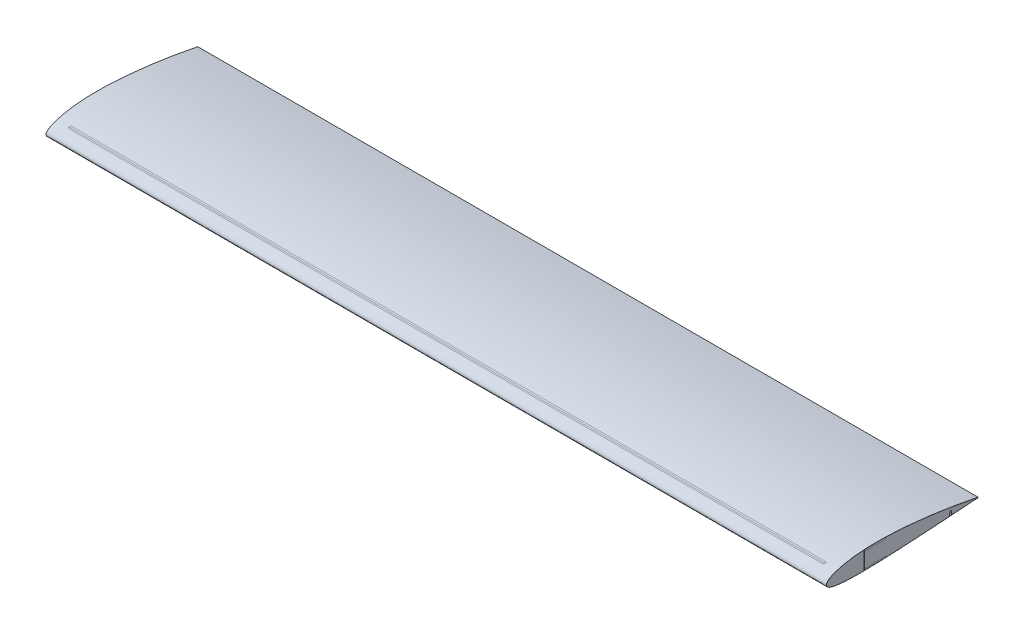
from build123d import *

# Parameters (mm, degrees)
BOSS_EXTRUDE1_DEPTH      = 914.4
SPLIT1_SURFACE_1_1_BACK  = 1864.333
SPLIT1_SURFACE_1_1_DEPTH = 3728.666
SPLIT1_SURFACE_1_2_BACK  = 1864.333
SPLIT1_SURFACE_1_2_DEPTH = 3728.666
SPLIT1_SURFACE_2_3_BACK  = 1864.333
SPLIT1_SURFACE_2_3_DEPTH = 3728.666
SPLIT1_SURFACE_2_4_BACK  = 1864.333
SPLIT1_SURFACE_2_4_DEPTH = 3728.666
CUT_EXTRUDE2_DEPTH       = 1864.047955072
CUT_EXTRUDE2_DEPTH_BACK  = 1864.047955072
SKETCH5_W                = 0.6096
SKETCH5_H                = 41.97587398
BOSS_EXTRUDE3_DEPTH      = 914.4
CUT_EXTRUDE1_DEPTH       = 982.342251229
CUT_EXTRUDE1_DEPTH_BACK  = 982.342251229
CUT_EXTRUDE3_START       = -15.24
SKETCH7_W                = 88.9
SKETCH7_H                = 50.8
SKETCH7_W_2              = 70
SKETCH7_H_2              = 60
CUT_EXTRUDE3_DEPTH       = 30


with BuildPart() as part:
    # Sketch3 → Boss-Extrude1 (new, symmetric)
    with BuildSketch(Plane(origin=(0, 0, 0), x_dir=(0, 0, -1), z_dir=(1, 0, 0))):
        with BuildLine():
            Line((354.482395792, 0.088620593), (354.482404208, -0.088620593))
            add(Edge.make_bspline(
                [(354.482395792, 0.088620593), (352.608228452, 0.482962912), (348.863032635, 1.270987104), (343.239204367, 2.400705172), (337.619234196, 3.501205803), (332.00350741, 4.57336723), (326.39365094, 5.621708723), (320.790955975, 6.647898692), (313.3412437, 7.986206456), (302.217548708, 9.927124821), (289.282248172, 12.069306379), (276.418289617, 14.074375479), (265.490213834, 15.689685159), (251.115583129, 17.697647921), (236.873997635, 19.516706822), (222.782191073, 21.1545078), (212.410278806, 22.282196191), (202.181522544, 23.317263374), (192.106178265, 24.258738007), (182.194355765, 25.104010981), (172.455993609, 25.84914195), (161.366752116, 26.592136123), (149.021873138, 27.260173986), (135.523535242, 27.752901504), (122.520585026, 27.971703259), (110.042618811, 27.912632335), (99.358952427, 27.613925108), (90.383015498, 27.176611302), (83.018255857, 26.691704891), (75.92680001, 26.098801968), (69.115792956, 25.403560206), (62.592086687, 24.612075224), (56.362219308, 23.730740073), (50.432432253, 22.76613435), (44.808681252, 21.725005613), (39.496589414, 20.614286523), (35.273389174, 19.622414223), (31.312122611, 18.607678857), (28.30479813, 17.772072592), (25.414040275, 16.897477013), (23.365017286, 16.242283662), (21.399313086, 15.577802598), (19.517418849, 14.904921007), (17.719798231, 14.224519318), (16.006896794, 13.537442329), (14.379132199, 12.844514757), (12.83689884, 12.146526839), (11.380573945, 11.444212218), (10.010495431, 10.738285126), (8.72699723, 10.029363811), (7.530365935, 9.318048232), (6.420876343, 8.604847497), (5.398771977, 7.890203754), (4.464271107, 7.174487774), (3.617571137, 6.457983471), (2.858851273, 5.740891979), (2.188290996, 5.02331412), (1.606069933, 4.305271505), (1.112414132, 3.586696787), (0.707594428, 2.867468864), (0.392035275, 2.147467241), (0.165980955, 1.426648517), (0.03064104, 0.705108282), (-0.015062322, 0.002321998), (0.0300091, -0.681067808), (0.166233189, -1.342726293), (0.392064116, -1.999419221), (0.707750679, -2.648952207), (1.11267333, -3.289391709), (1.606518652, -3.919009399), (2.188985401, -4.536239368), (2.859837198, -5.139669278), (3.618875057, -5.728012998), (4.465910314, -6.300126202), (5.400751117, -6.855005762), (6.423189663, -7.391813529), (7.532996553, -7.909871987), (8.729927186, -8.408651764), (10.013701883, -8.887797325), (11.38402716, -9.347075258), (12.840573178, -9.786424712), (14.382996464, -10.205871846), (16.010922843, -10.605571954), (17.723957882, -10.985755667), (19.521682855, -11.346729932), (21.403657483, -11.688838297), (23.369418393, -12.012454984), (25.418477351, -12.317982315), (27.550327067, -12.60579833), (29.764437774, -12.876267774), (32.06025868, -13.129726833), (35.281637131, -13.450564772), (39.508953014, -13.807595259), (44.820372176, -14.165273739), (50.443395574, -14.459314626), (56.372426035, -14.689735484), (62.601520751, -14.856376302), (69.124436068, -14.959259527), (75.934620245, -14.999005808), (83.025208132, -14.977114302), (90.389050421, -14.896168064), (98.01873047, -14.759786253), (105.906589977, -14.572414932), (114.044705159, -14.338950875), (122.424896468, -14.064247122), (131.038747414, -13.752531546), (139.877603076, -13.406970238), (148.932577206, -13.029259309), (161.41234267, -12.47716831), (174.14861492, -11.863755741), (187.128161714, -11.181855227), (197.122814271, -10.626100485), (207.275853505, -10.030722137), (219.334002974, -9.289918707), (231.549233078, -8.503762909), (243.909719078, -7.688473483), (254.646983505, -6.974941746), (263.659566191, -6.37740606), (272.749168182, -5.777991417), (281.906666981, -5.177313299), (292.948412975, -4.453461563), (302.190318, -3.838787226), (309.611800723, -3.332601249), (315.195965568, -2.943756386), (320.789989327, -2.54505907), (326.392440618, -2.136294162), (332.001878993, -1.718848953), (337.616855999, -1.295823565), (343.235982568, -0.874824171), (348.857573789, -0.461772871), (352.607516747, -0.21300097), (354.482404208, -0.088620593)],
                knots=[0, 0, 0, 0, 0.007940543, 0.015867786, 0.023782336, 0.031683842, 0.039571466, 0.047443805, 0.055299407, 0.070952907, 0.094259966, 0.109659749, 0.124931368, 0.140060475, 0.169836167, 0.184455938, 0.198878988, 0.213091981, 0.227081364, 0.240833733, 0.254335896, 0.267574898, 0.286913018, 0.305591757, 0.323574751, 0.340828862, 0.357323531, 0.367884026, 0.378086462, 0.387923234, 0.397387015, 0.406470797, 0.41516795, 0.423472244, 0.43137777, 0.438879022, 0.445971139, 0.449362331, 0.455832514, 0.458910652, 0.461883669, 0.464751272, 0.467513247, 0.470169459, 0.472719872, 0.475164567, 0.477503762, 0.479737826, 0.481867333, 0.483893084, 0.485816152, 0.487637951, 0.489360303, 0.49098553, 0.492516542, 0.493957004, 0.495311466, 0.496585561, 0.4977862, 0.498921787, 0.500002352, 0.50103964, 0.502046987, 0.503038995, 0.503951731, 0.504878158, 0.505831393, 0.506823576, 0.507865603, 0.508967032, 0.510136107, 0.511379885, 0.512704371, 0.51411466, 0.515615093, 0.517209348, 0.518900571, 0.520691419, 0.522584144, 0.524580638, 0.526682478, 0.528890964, 0.531207133, 0.533631806, 0.536165599, 0.538808937, 0.541562081, 0.544425147, 0.547398108, 0.550480817, 0.553673027, 0.556974385, 0.563902733, 0.571261381, 0.579045037, 0.58724742, 0.595861595, 0.604880098, 0.614294871, 0.624097261, 0.634278056, 0.644827522, 0.655735355, 0.666990799, 0.678582536, 0.690498843, 0.702727789, 0.715257042, 0.728074047, 0.754520377, 0.768123571, 0.781962351, 0.796022904, 0.810291085, 0.832050541, 0.846772874, 0.861649926, 0.876666219, 0.884221743, 0.899417941, 0.914715475, 0.9300999, 0.937820202, 0.945556969, 0.953308312, 0.961072259, 0.968846879, 0.976629764, 0.984418334, 0.992209516, 1, 1, 1, 1], degree=3))
        make_face()
    extrude(amount=BOSS_EXTRUDE1_DEPTH, both=True)


with BuildPart() as body_2:
    # Split1: the piece behind the surface
    add(part.part)
    # Split1 surface 1: a surface, the sketch's curves swept straight by 3728.666 mm
    with BuildLine(Plane(origin=(914.4, 0, 0), x_dir=(0, 0, -1), z_dir=(1, 0, 0)).offset(-SPLIT1_SURFACE_1_1_BACK), mode=Mode.PRIVATE) as split1_surface_1_1_path:
        Line((139.692248422, -14.02064701), (139.692248422, -10.84564701))
        Line((139.692248422, -10.84564701), (88.9, -11.733059128))
        Line((88.9, -11.733059128), (88.9, -14.908059128))
    split1_surface_1_1 = Shell.extrude(split1_surface_1_1_path.wire(), (1 * SPLIT1_SURFACE_1_1_DEPTH, 0 * SPLIT1_SURFACE_1_1_DEPTH, 0 * SPLIT1_SURFACE_1_1_DEPTH))
    split(bisect_by=split1_surface_1_1, keep=Keep.BOTTOM)


with BuildPart() as part_1:
    add(part.part)

    # Split1: split by a surface, the side it looks to stays
    # Split1 surface 1: a surface, the sketch's curves swept straight by 3728.666 mm
    with BuildLine(Plane(origin=(914.4, 0, 0), x_dir=(0, 0, -1), z_dir=(1, 0, 0)).offset(-SPLIT1_SURFACE_1_2_BACK), mode=Mode.PRIVATE) as split1_surface_1_2_path:
        Line((139.692248422, -14.02064701), (139.692248422, -10.84564701))
        Line((139.692248422, -10.84564701), (88.9, -11.733059128))
        Line((88.9, -11.733059128), (88.9, -14.908059128))
    split1_surface_1_2 = Shell.extrude(split1_surface_1_2_path.wire(), (1 * SPLIT1_SURFACE_1_2_DEPTH, 0 * SPLIT1_SURFACE_1_2_DEPTH, 0 * SPLIT1_SURFACE_1_2_DEPTH))
    split(bisect_by=split1_surface_1_2, keep=Keep.TOP)


with BuildPart() as body_3:
    # Split1 2 body 2: the piece behind the surface
    add(body_2.part)
    # Split1 surface 2: a surface, the sketch's curves swept straight by 3728.666 mm
    with BuildLine(Plane(origin=(914.4, 0, 0), x_dir=(0, 0, -1), z_dir=(1, 0, 0)).offset(-SPLIT1_SURFACE_2_3_BACK), mode=Mode.PRIVATE) as split1_surface_2_3_path:
        Line((139.7, 27.585057341), (139.7, 23.892814852))
        Line((139.7, 23.892814852), (88.9, 23.892814852))
        Line((88.9, 23.892814852), (88.9, 27.067814852))
    split1_surface_2_3 = Shell.extrude(split1_surface_2_3_path.wire(), (1 * SPLIT1_SURFACE_2_3_DEPTH, 0 * SPLIT1_SURFACE_2_3_DEPTH, 0 * SPLIT1_SURFACE_2_3_DEPTH))
    split(bisect_by=split1_surface_2_3, keep=Keep.BOTTOM)


with BuildPart() as body_2_1:
    add(body_2.part)

    # Split1 2 body 2: split by a surface, the side it looks to stays
    # Split1 surface 2: a surface, the sketch's curves swept straight by 3728.666 mm
    with BuildLine(Plane(origin=(914.4, 0, 0), x_dir=(0, 0, -1), z_dir=(1, 0, 0)).offset(-SPLIT1_SURFACE_2_4_BACK), mode=Mode.PRIVATE) as split1_surface_2_4_path:
        Line((139.7, 27.585057341), (139.7, 23.892814852))
        Line((139.7, 23.892814852), (88.9, 23.892814852))
        Line((88.9, 23.892814852), (88.9, 27.067814852))
    split1_surface_2_4 = Shell.extrude(split1_surface_2_4_path.wire(), (1 * SPLIT1_SURFACE_2_4_DEPTH, 0 * SPLIT1_SURFACE_2_4_DEPTH, 0 * SPLIT1_SURFACE_2_4_DEPTH))
    split(bisect_by=split1_surface_2_4, keep=Keep.TOP)

    # Sketch5 → Cut-Extrude2 (cut, two sides: drawn at the far end of the back side and taken through both)
    with BuildSketch(Plane(origin=(914.4, 0, 0), x_dir=(0, 0, -1), z_dir=(1, 0, 0)).offset(-CUT_EXTRUDE2_DEPTH_BACK)):
        with Locations((88.5952, 6.079877862)):
            Rectangle(SKETCH5_W, SKETCH5_H)
    extrude(amount=CUT_EXTRUDE2_DEPTH + CUT_EXTRUDE2_DEPTH_BACK, mode=Mode.SUBTRACT)


with BuildPart() as cut_extrude2_piece_1:
    # of the separate pieces the step leaves, piece 1, a body of its own (cut_extrude2_pieces)
    add(body_2_1.part.solids().sort_by_distance((0, 0.088620593, -354.482395792))[0])

    # Sketch3_3 → Cut-Extrude1 (cut, two sides: drawn at the far end of the back side and taken through both)
    with BuildSketch(Plane(origin=(0, 0, 0), x_dir=(0, 0, -1), z_dir=(1, 0, 0)).offset(-CUT_EXTRUDE1_DEPTH_BACK)):
        Polygon((290.9824, 7.62), (287.654397763, -4.800273435), (290.9824, -6.35), (294.194928457, -4.369319423), align=None)
    extrude(amount=CUT_EXTRUDE1_DEPTH + CUT_EXTRUDE1_DEPTH_BACK, mode=Mode.SUBTRACT)


with BuildPart() as cut_extrude2_piece_2:
    # of the separate pieces the step leaves, piece 2, a body of its own (cut_extrude2_pieces)
    add(body_2_1.part.solids().sort_by_distance((-914.4, 27.030418138, -88.2904))[0])


with BuildPart() as body_5:
    # Sketch3_4 → Boss-Extrude3 (new, symmetric)
    with BuildSketch(Plane(origin=(0, 0, 0), x_dir=(0, 0, -1), z_dir=(1, 0, 0))):
        with BuildLine():
            Line((355.091972301, 0.583307998), (355.0920313, -0.659117779))
            add(Edge.make_bspline(
                [(355.091972301, 0.583307998), (340.312721276, 3.693000498), (310.619909788, 9.275193539), (265.886786743, 16.489468956), (228.423488563, 21.249575809), (198.375428006, 24.346944526), (175.800462925, 26.279897889), (153.185851558, 27.734389131), (130.534341141, 28.566890102), (111.639670243, 28.595066064), (96.53057426, 28.120840782), (85.209090536, 27.490139036), (73.906703798, 26.554481442), (62.635164397, 25.277209771), (51.411056679, 23.609637495), (42.117578054, 21.837331865), (34.74012523, 20.134439319), (29.24437833, 18.69364882), (23.79825163, 17.061014615), (18.420286663, 15.195924919), (13.14366618, 13.032592163), (8.880173336, 10.889148982), (5.630848338, 8.846659986), (3.323741515, 7.086461913), (1.245271009, 5.003310853), (-0.100437746, 2.836873377), (-0.523145833, 1.190618683), (-0.61337565, 0.27223844), (-0.614549748, -0.263820978), (-0.519523355, -1.17728836), (-0.186155394, -2.32203817), (0.846863121, -4.107713514), (2.649273044, -5.870048972), (5.118512155, -7.455426547), (7.737103362, -8.698049302), (11.332776407, -10.034608615), (15.937246254, -11.276874703), (21.529341018, -12.368534166), (27.15473911, -13.195901809), (32.797240174, -13.837752171), (40.333864658, -14.507839139), (49.769089576, -15.075023465), (61.099652807, -15.458479805), (72.432280744, -15.614977761), (83.76344512, -15.594566474), (95.091473866, -15.436956689), (109.964247113, -15.092784384), (122.943936948, -14.66400478), (135.920562744, -14.174609397), (143.690347914, -13.860725655), (157.116288121, -13.285023495), (174.310683531, -12.480653893), (196.927788923, -11.269252396), (227.071310703, -9.442589353), (257.19655476, -7.405393554), (287.324528389, -5.43433642), (309.922117903, -3.947040671), (332.514912298, -2.303371631), (347.562013118, -1.158660561), (355.0920313, -0.659117779)],
                knots=[-0.000683627, -0.000683627, -0.000683627, -0.000683627, 0.06190838, 0.124500386, 0.187092393, 0.218388396, 0.249684399, 0.280980403, 0.312276406, 0.343572409, 0.359220411, 0.374868413, 0.390516414, 0.406164416, 0.421812418, 0.437460419, 0.44528442, 0.453108421, 0.460932422, 0.468756423, 0.476580423, 0.484404424, 0.488316425, 0.492228425, 0.496140425, 0.500052426, 0.502008426, 0.502526747, 0.503504747, 0.503993747, 0.505920426, 0.507876427, 0.511788427, 0.515700428, 0.519612428, 0.523524428, 0.531348429, 0.53917243, 0.546996431, 0.554820432, 0.562644432, 0.578292434, 0.593940436, 0.609588437, 0.625236439, 0.640884441, 0.656532442, 0.686889741, 0.694713742, 0.710361744, 0.719124449, 0.750420452, 0.781716456, 0.813012459, 0.875604465, 0.906900469, 0.938196472, 0.969492475, 1.000788479, 1.000788479, 1.000788479, 1.000788479], degree=3))
        make_face()
        with BuildLine():
            Line((354.482395792, 0.088620593), (354.482404208, -0.088620593))
            add(Edge.make_bspline(
                [(354.482395792, 0.088620593), (352.608228452, 0.482962912), (348.863032635, 1.270987104), (343.239204367, 2.400705172), (337.619234196, 3.501205803), (332.00350741, 4.57336723), (326.39365094, 5.621708723), (320.790955975, 6.647898692), (313.3412437, 7.986206456), (302.217548708, 9.927124821), (289.282248172, 12.069306379), (276.418289617, 14.074375479), (265.490213834, 15.689685159), (251.115583129, 17.697647921), (236.873997635, 19.516706822), (222.782191073, 21.1545078), (212.410278806, 22.282196191), (202.181522544, 23.317263374), (192.106178265, 24.258738007), (182.194355765, 25.104010981), (172.455993609, 25.84914195), (161.366752116, 26.592136123), (149.021873138, 27.260173986), (135.523535242, 27.752901504), (122.520585026, 27.971703259), (110.042618811, 27.912632335), (99.358952427, 27.613925108), (90.383015498, 27.176611302), (83.018255857, 26.691704891), (75.92680001, 26.098801968), (69.115792956, 25.403560206), (62.592086687, 24.612075224), (56.362219308, 23.730740073), (50.432432253, 22.76613435), (44.808681252, 21.725005613), (39.496589414, 20.614286523), (35.273389174, 19.622414223), (31.312122611, 18.607678857), (28.30479813, 17.772072592), (25.414040275, 16.897477013), (23.365017286, 16.242283662), (21.399313086, 15.577802598), (19.517418849, 14.904921007), (17.719798231, 14.224519318), (16.006896794, 13.537442329), (14.379132199, 12.844514757), (12.83689884, 12.146526839), (11.380573945, 11.444212218), (10.010495431, 10.738285126), (8.72699723, 10.029363811), (7.530365935, 9.318048232), (6.420876343, 8.604847497), (5.398771977, 7.890203754), (4.464271107, 7.174487774), (3.617571137, 6.457983471), (2.858851273, 5.740891979), (2.188290996, 5.02331412), (1.606069933, 4.305271505), (1.112414132, 3.586696787), (0.707594428, 2.867468864), (0.392035275, 2.147467241), (0.165980955, 1.426648517), (0.03064104, 0.705108282), (-0.015062322, 0.002321998), (0.0300091, -0.681067808), (0.166233189, -1.342726293), (0.392064116, -1.999419221), (0.707750679, -2.648952207), (1.11267333, -3.289391709), (1.606518652, -3.919009399), (2.188985401, -4.536239368), (2.859837198, -5.139669278), (3.618875057, -5.728012998), (4.465910314, -6.300126202), (5.400751117, -6.855005762), (6.423189663, -7.391813529), (7.532996553, -7.909871987), (8.729927186, -8.408651764), (10.013701883, -8.887797325), (11.38402716, -9.347075258), (12.840573178, -9.786424712), (14.382996464, -10.205871846), (16.010922843, -10.605571954), (17.723957882, -10.985755667), (19.521682855, -11.346729932), (21.403657483, -11.688838297), (23.369418393, -12.012454984), (25.418477351, -12.317982315), (27.550327067, -12.60579833), (29.764437774, -12.876267774), (32.06025868, -13.129726833), (35.281637131, -13.450564772), (39.508953014, -13.807595259), (44.820372176, -14.165273739), (50.443395574, -14.459314626), (56.372426035, -14.689735484), (62.601520751, -14.856376302), (69.124436068, -14.959259527), (75.934620245, -14.999005808), (83.025208132, -14.977114302), (90.389050421, -14.896168064), (98.01873047, -14.759786253), (105.906589977, -14.572414932), (114.044705159, -14.338950875), (122.424896468, -14.064247122), (131.038747414, -13.752531546), (139.877603076, -13.406970238), (148.932577206, -13.029259309), (161.41234267, -12.47716831), (174.14861492, -11.863755741), (187.128161714, -11.181855227), (197.122814271, -10.626100485), (207.275853505, -10.030722137), (219.334002974, -9.289918707), (231.549233078, -8.503762909), (243.909719078, -7.688473483), (254.646983505, -6.974941746), (263.659566191, -6.37740606), (272.749168182, -5.777991417), (281.906666981, -5.177313299), (292.948412975, -4.453461563), (302.190318, -3.838787226), (309.611800723, -3.332601249), (315.195965568, -2.943756386), (320.789989327, -2.54505907), (326.392440618, -2.136294162), (332.001878993, -1.718848953), (337.616855999, -1.295823565), (343.235982568, -0.874824171), (348.857573789, -0.461772871), (352.607516747, -0.21300097), (354.482404208, -0.088620593)],
                knots=[0, 0, 0, 0, 0.007940543, 0.015867786, 0.023782336, 0.031683842, 0.039571466, 0.047443805, 0.055299407, 0.070952907, 0.094259966, 0.109659749, 0.124931368, 0.140060475, 0.169836167, 0.184455938, 0.198878988, 0.213091981, 0.227081364, 0.240833733, 0.254335896, 0.267574898, 0.286913018, 0.305591757, 0.323574751, 0.340828862, 0.357323531, 0.367884026, 0.378086462, 0.387923234, 0.397387015, 0.406470797, 0.41516795, 0.423472244, 0.43137777, 0.438879022, 0.445971139, 0.449362331, 0.455832514, 0.458910652, 0.461883669, 0.464751272, 0.467513247, 0.470169459, 0.472719872, 0.475164567, 0.477503762, 0.479737826, 0.481867333, 0.483893084, 0.485816152, 0.487637951, 0.489360303, 0.49098553, 0.492516542, 0.493957004, 0.495311466, 0.496585561, 0.4977862, 0.498921787, 0.500002352, 0.50103964, 0.502046987, 0.503038995, 0.503951731, 0.504878158, 0.505831393, 0.506823576, 0.507865603, 0.508967032, 0.510136107, 0.511379885, 0.512704371, 0.51411466, 0.515615093, 0.517209348, 0.518900571, 0.520691419, 0.522584144, 0.524580638, 0.526682478, 0.528890964, 0.531207133, 0.533631806, 0.536165599, 0.538808937, 0.541562081, 0.544425147, 0.547398108, 0.550480817, 0.553673027, 0.556974385, 0.563902733, 0.571261381, 0.579045037, 0.58724742, 0.595861595, 0.604880098, 0.614294871, 0.624097261, 0.634278056, 0.644827522, 0.655735355, 0.666990799, 0.678582536, 0.690498843, 0.702727789, 0.715257042, 0.728074047, 0.754520377, 0.768123571, 0.781962351, 0.796022904, 0.810291085, 0.832050541, 0.846772874, 0.861649926, 0.876666219, 0.884221743, 0.899417941, 0.914715475, 0.9300999, 0.937820202, 0.945556969, 0.953308312, 0.961072259, 0.968846879, 0.976629764, 0.984418334, 0.992209516, 1, 1, 1, 1], degree=3))
        make_face(mode=Mode.SUBTRACT)
    extrude(amount=BOSS_EXTRUDE3_DEPTH, both=True)


with BuildPart() as cut_extrude3_tool:
    # Sketch7 → Cut-Extrude3 (new body)
    with BuildSketch(Plane(origin=(0, 0, 0), x_dir=(1, 0, 0), z_dir=(0, 1, 0)).offset(CUT_EXTRUDE3_START)):
        with Locations((323.85, 165.092248423)):
            Rectangle(SKETCH7_W, SKETCH7_H)
        with Locations((625.4, 169.692248423)):
            Rectangle(SKETCH7_W_2, SKETCH7_H_2)
        with Locations((193.75, 169.692248423)):
            Rectangle(SKETCH7_W_2, SKETCH7_H_2)
        with Locations((-193.75, 169.692248423)):
            Rectangle(SKETCH7_W_2, SKETCH7_H_2)
        with Locations((-323.85, 165.092248423)):
            Rectangle(SKETCH7_W, SKETCH7_H)
        with Locations((-625.4, 169.692248423)):
            Rectangle(SKETCH7_W_2, SKETCH7_H_2)
    extrude(amount=CUT_EXTRUDE3_DEPTH)


with BuildPart() as cut_extrude2_piece_1_1:
    add(cut_extrude2_piece_1.part)

    # Cut-Extrude3: cut by cut_extrude3_tool
    add(cut_extrude3_tool.part, mode=Mode.SUBTRACT)


with BuildPart() as body_5_1:
    add(body_5.part)

    # Cut-Extrude3: cut by cut_extrude3_tool
    add(cut_extrude3_tool.part, mode=Mode.SUBTRACT)


solid = Compound([part_1.part, body_3.part, cut_extrude2_piece_2.part, cut_extrude2_piece_1_1.part, body_5_1.part])
